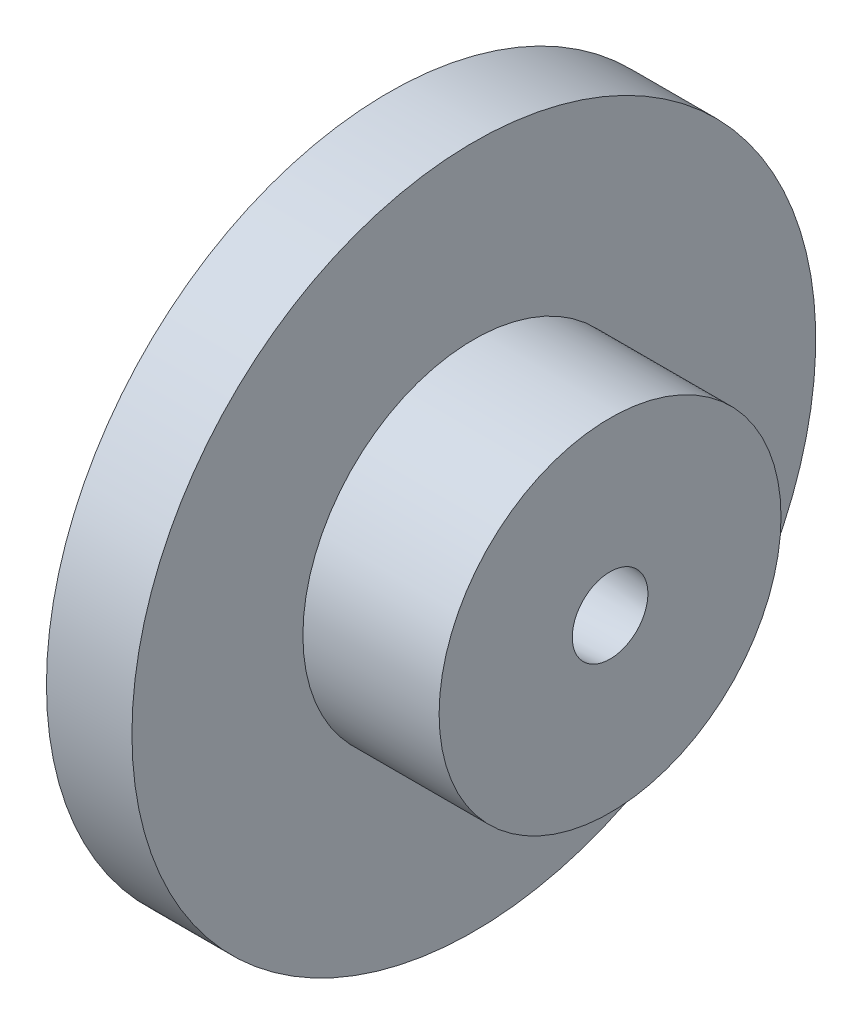
from build123d import *


with BuildPart() as part:
    # Sketch1 → Revolve1 (revolve)
    with BuildSketch(Plane.XY):
        Polygon((0, 8.500000018), (0, 50.8), (12.7, 50.8), (12.7, 25.4), (32.939999906, 25.4), (32.939999906, 5.61812345), align=None)
    revolve(axis=Axis((0, 0, 0), (1, 0, 0)))


solid = part.part
